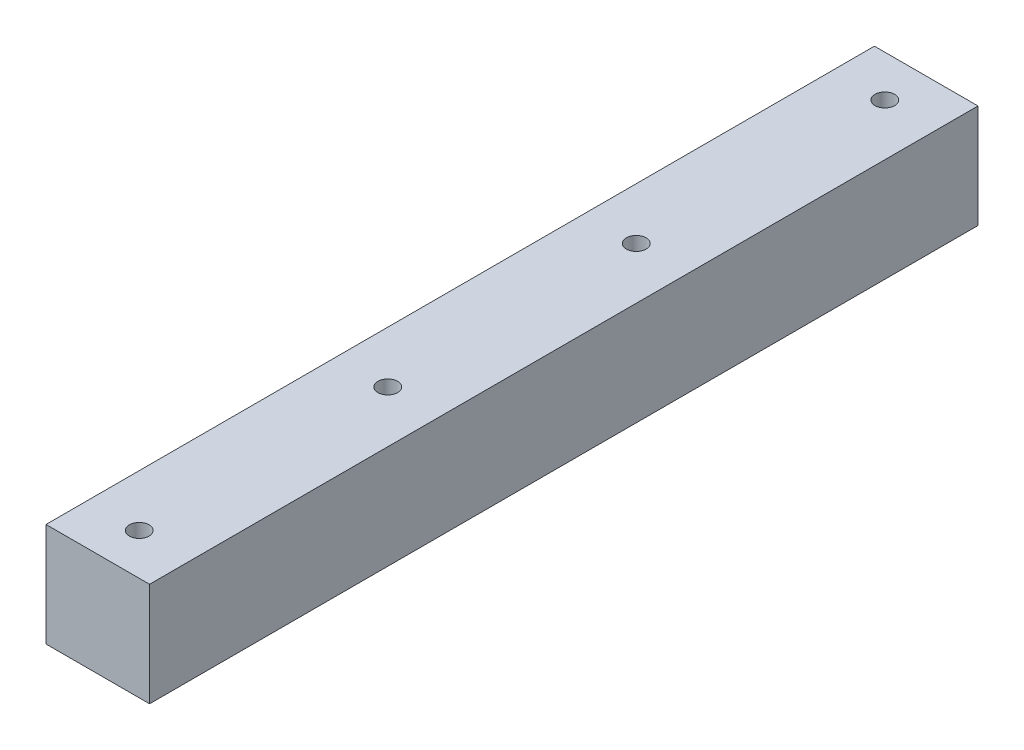
from build123d import *

# Parameters (mm, degrees)
SKIZZE1_W                       = 50
SKIZZE1_H                       = 400
AUFSATZ_LINEAR_AUSTRAGEN1_DEPTH = 50
LINEARES_MUSTER1_COUNT          = 4
LINEARES_MUSTER1_PITCH          = 120


with BuildPart() as part:
    # Skizze1 → Aufsatz-Linear austragen1 (new body)
    with BuildSketch(Plane(origin=(0, 0, 0), x_dir=(1, 0, 0), z_dir=(0, 1, 0))):
        Rectangle(SKIZZE1_W, SKIZZE1_H)
    extrude(amount=AUFSATZ_LINEAR_AUSTRAGEN1_DEPTH)

    # Skizze2 → Ø9.5 (9.5) Durchmesser Bohrung1 (revolve, cut)
    with BuildSketch(Plane(origin=(0, 50, 180), x_dir=(0, 0, 1), z_dir=(1, 0, 0))):
        Polygon((0, 0), (0, 22.85408794), (4.75, 20), (4.75, 0), align=None)
    f_9_5_9_5_durchmesser_bohrung1 = revolve(axis=Axis((0, 56.35, 180), (0, -1, 0)), mode=Mode.SUBTRACT)

    # Lineares Muster1: Ø9.5 (9.5) Durchmesser Bohrung1 ×4
    with Locations(*[(0, 0, -i * LINEARES_MUSTER1_PITCH) for i in range(1, LINEARES_MUSTER1_COUNT)]):
        add(f_9_5_9_5_durchmesser_bohrung1, mode=Mode.SUBTRACT)


solid = part.part
